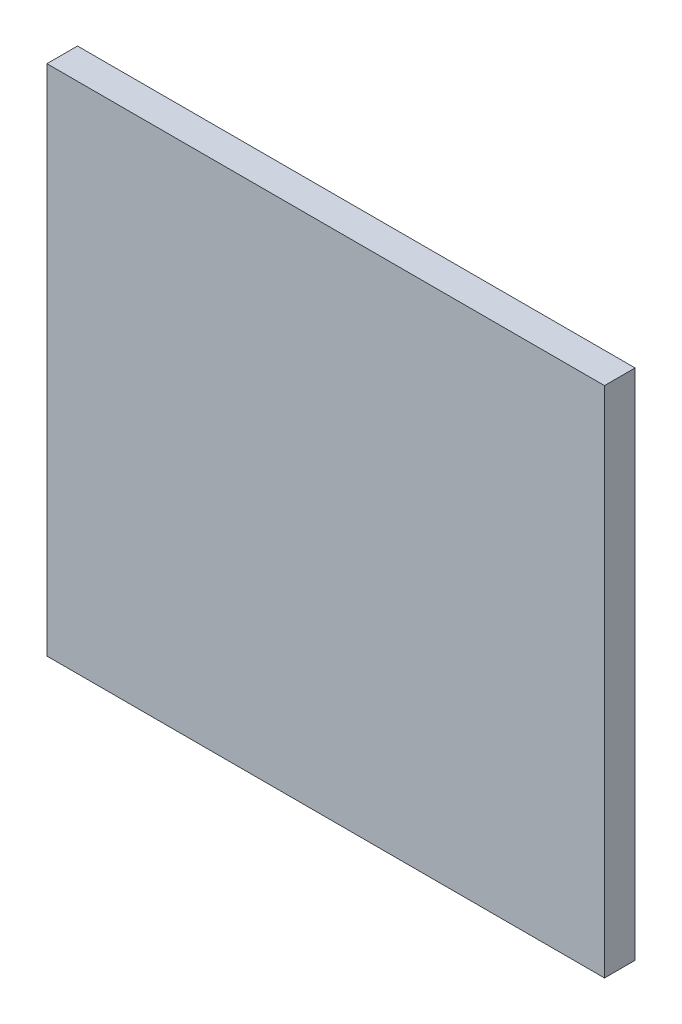
from build123d import *

# Parameters (mm, degrees)
EXTRUDE_1_DEPTH      = 790
EXTRUDE_1_DEPTH_BACK = 790
SKETCH_1_W           = 28800
SKETCH_1_H           = 26500


with BuildPart() as part:
    # Эскиз1 → Бобышка-Вытянуть1 (new, two sides: drawn at the far end of the back side and taken through both)
    with BuildSketch(Plane.XY.offset(-EXTRUDE_1_DEPTH_BACK)):
        with Locations((607.442987237, 182.941623523)):
            Rectangle(SKETCH_1_W, SKETCH_1_H)
    extrude(amount=EXTRUDE_1_DEPTH + EXTRUDE_1_DEPTH_BACK)


solid = part.part
